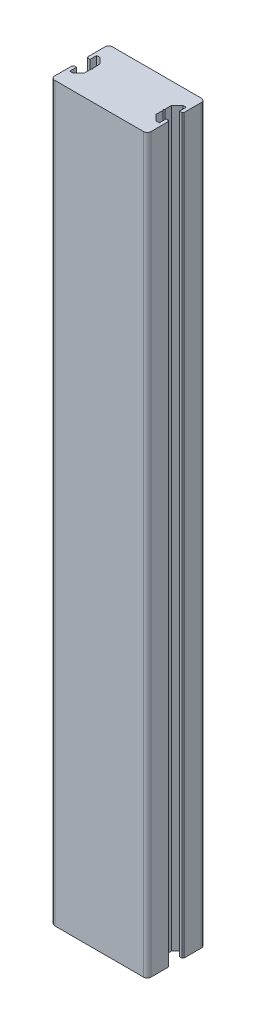
from build123d import *

# Parameters (mm, degrees)
BOSS_EXTRUDE1_DEPTH = 570
FILLET1_R           = 3


with BuildPart() as part:
    # Sketch1 → Boss-Extrude1 (new body)
    with BuildSketch(Plane(origin=(0, 0, 0), x_dir=(1, 0, 0), z_dir=(0, 1, 0))):
        with BuildLine():
            Line((2.625, 17.250000178), (0.75, 17.250000178))
            ThreePointArc((0.75, 17.250000178), (0.530330086, 16.719670092), (0, 16.500000178))
            Line((0, 16.500000178), (0, 0))
            Line((0, 0), (75, 0))
            Line((75, 0), (75, 16.500000178))
            ThreePointArc((75, 16.500000178), (74.469669914, 16.719670092), (74.25, 17.250000178))
            Line((74.25, 17.250000178), (72.375, 17.250000178))
            Line((72.375, 17.250000178), (72.375, 12.000000178))
            Line((72.375, 12.000000178), (69.75, 12.000000178))
            Line((69.75, 12.000000178), (65.375, 16.375))
            Line((65.375, 16.375), (65.375, 21.75))
            Line((65.375, 21.75), (64.625, 22.5))
            Line((64.625, 22.5), (65.375, 23.25))
            Line((65.375, 23.25), (65.375, 28.625))
            Line((65.375, 28.625), (69.75, 33.000000178))
            Line((69.75, 33.000000178), (72.375, 33.000000178))
            Line((72.375, 33.000000178), (72.375, 27.750000178))
            Line((72.375, 27.750000178), (74.25, 27.750000178))
            ThreePointArc((74.25, 27.750000178), (74.469669914, 28.280330264), (75, 28.500000178))
            Line((75, 28.500000178), (75, 45))
            Line((75, 45), (0, 45))
            Line((0, 45), (0, 28.500000178))
            ThreePointArc((0, 28.500000178), (0.530330086, 28.280330264), (0.75, 27.750000178))
            Line((0.75, 27.750000178), (2.625, 27.750000178))
            Line((2.625, 27.750000178), (2.625, 33.000000178))
            Line((2.625, 33.000000178), (5.25, 33.000000178))
            Line((5.25, 33.000000178), (9.625, 28.625))
            Line((9.625, 28.625), (9.625, 23.25))
            Line((9.625, 23.25), (10.375, 22.5))
            Line((10.375, 22.5), (9.625, 21.75))
            Line((9.625, 21.75), (9.625, 16.375))
            Line((9.625, 16.375), (5.25, 12.000000178))
            Line((5.25, 12.000000178), (2.625, 12.000000178))
            Line((2.625, 12.000000178), (2.625, 17.250000178))
        make_face()
    extrude(amount=BOSS_EXTRUDE1_DEPTH)

    # Fillet1
    fillet1_edges = [part.edges().sort_by_distance(p)[0] for p in [
        (0, 285, 0),
        (0, 285, -45),
        (75, 285, -45),
        (75, 285, 0),
    ]]
    fillet(fillet1_edges, radius=FILLET1_R)


solid = part.part
